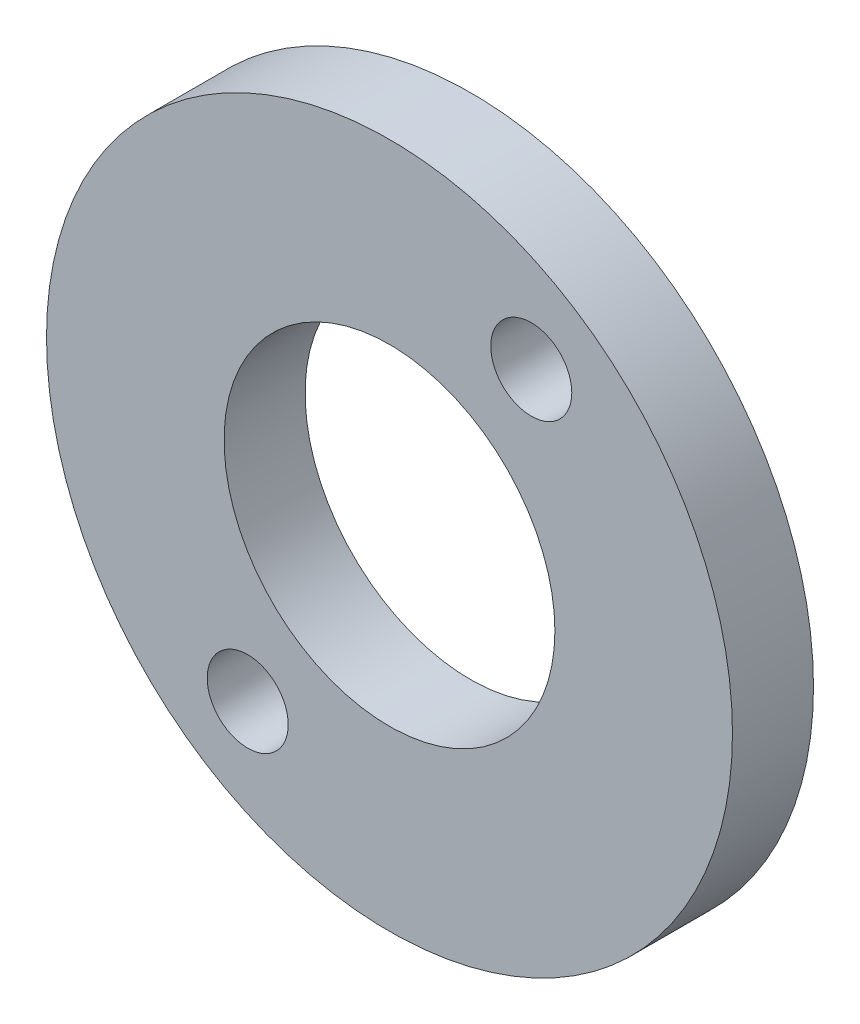
from build123d import *

# Parameters (mm, degrees)
SKETCH2_R           = 12.7
SKETCH2_R_2         = 6.125
SKETCH2_R_3         = 1.5
BOSS_EXTRUDE1_DEPTH = 3


with BuildPart() as part:
    # Sketch2 → Boss-Extrude1 (new body)
    with BuildSketch(Plane.XY.offset(129.258321615)):
        with Locations((-25.912099998, -505.146272004)):
            Circle(SKETCH2_R)
        with Locations((-25.912099998, -505.146272004)):
            Circle(SKETCH2_R_2, mode=Mode.SUBTRACT)
        with Locations((-31.162099998, -513.093795204)):
            Circle(SKETCH2_R_3, mode=Mode.SUBTRACT)
        with Locations((-20.662099998, -497.198748805)):
            Circle(SKETCH2_R_3, mode=Mode.SUBTRACT)
    extrude(amount=BOSS_EXTRUDE1_DEPTH)


solid = part.part
